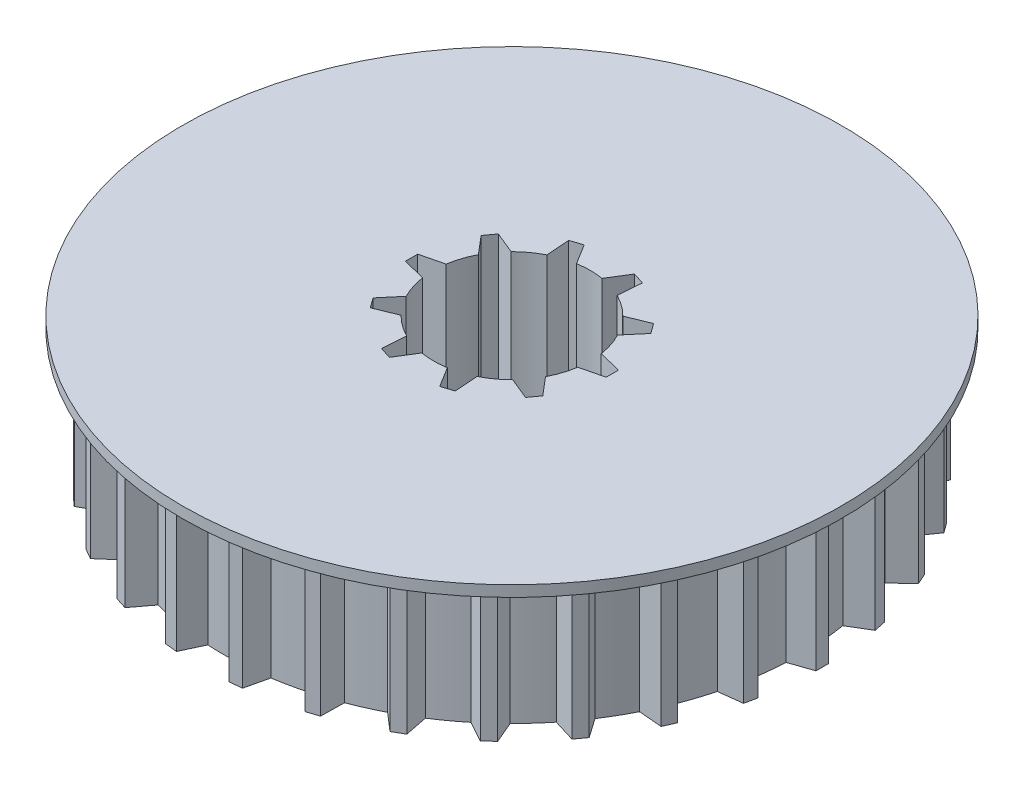
from build123d import *

# Parameters (mm, degrees)
BOSS_EXTRUDE1_DEPTH = 6.3
CIRPATTERN1_COUNT   = 30
SKETCH2_R           = 15
BOSS_EXTRUDE2_DEPTH = 0.5
CUT_EXTRUDE2_DEPTH  = 7.8
CIRPATTERN2_COUNT   = 10


with BuildPart() as part:
    # Sketch1 → Boss-Extrude1 (new body)
    with BuildSketch(Plane(origin=(0, 0, 0), x_dir=(1, 0, 0), z_dir=(0, 1, 0))):
        with BuildLine():
            ThreePointArc((13.104844929, 0.630427946), (-13.12, 0), (13.104844929, -0.630427946))
            Line((13.104844929, -0.630427946), (12.849932635, -0.718422769))
            ThreePointArc((12.849932635, -0.718422769), (12.87, 0), (12.849932635, 0.718422769))
            Line((12.849932635, 0.718422769), (13.104844929, 0.630427946))
        make_face()
        with BuildLine():
            Line((12.849932635, -0.718422769), (13.104844929, -0.630427946))
            ThreePointArc((13.104844929, -0.630427946), (13.116210685, -0.315305039), (13.12, 0))
            ThreePointArc((13.12, 0), (13.116210685, 0.315305039), (13.104844929, 0.630427946))
            Line((13.104844929, 0.630427946), (12.849932635, 0.718422769))
            ThreePointArc((12.849932635, 0.718422769), (12.87, 0), (12.849932635, -0.718422769))
        make_face()
        with BuildLine():
            Line((14.12, -0.28), (14.12, 0))
            Line((14.12, 0), (14.12, 0.28))
            Line((14.12, 0.28), (13.104844929, 0.630427946))
            ThreePointArc((13.104844929, 0.630427946), (13.116210685, 0.315305039), (13.12, 0))
            ThreePointArc((13.12, 0), (13.116210685, -0.315305039), (13.104844929, -0.630427946))
            Line((13.104844929, -0.630427946), (14.12, -0.28))
        make_face()
    boss_extrude1 = extrude(amount=BOSS_EXTRUDE1_DEPTH)

    # CirPattern1: Boss-Extrude1 ×30 about axis
    cirpattern1_axis = Axis((0, 0, 0), (0, 1, 0))
    for i in range(1, CIRPATTERN1_COUNT):
        add(boss_extrude1.rotate(cirpattern1_axis, i * 360 / CIRPATTERN1_COUNT))

    # Sketch2 → Boss-Extrude2 (add)
    with BuildSketch(Plane(origin=(0, 6.3, 0), x_dir=(1, 0, 0), z_dir=(0, 1, 0))):
        Circle(SKETCH2_R)
    extrude(amount=BOSS_EXTRUDE2_DEPTH)

    # Sketch5 → Cut-Extrude2 (cut, through all)
    with BuildSketch(Plane.XZ):
        with BuildLine():
            ThreePointArc((3.529675716, 0.535060126), (-3.57, 0), (3.529675716, -0.535060126))
            Line((3.529675716, -0.535060126), (3.265358075, -0.599863853))
            ThreePointArc((3.265358075, -0.599863853), (3.32, 0), (3.265358075, 0.599863853))
            Line((3.265358075, 0.599863853), (3.529675716, 0.535060126))
        make_face()
        with BuildLine():
            Line((3.265358075, -0.599863853), (3.529675716, -0.535060126))
            ThreePointArc((3.529675716, -0.535060126), (3.559904655, -0.268288737), (3.57, 0))
            ThreePointArc((3.57, 0), (3.559904655, 0.268288737), (3.529675716, 0.535060126))
            Line((3.529675716, 0.535060126), (3.265358075, 0.599863853))
            ThreePointArc((3.265358075, 0.599863853), (3.32, 0), (3.265358075, -0.599863853))
        make_face()
        with BuildLine():
            Line((4.57, -0.28), (4.57, 0))
            Line((4.57, 0), (4.57, 0.28))
            Line((4.57, 0.28), (3.529675716, 0.535060126))
            ThreePointArc((3.529675716, 0.535060126), (3.559904655, 0.268288737), (3.57, 0))
            ThreePointArc((3.57, 0), (3.559904655, -0.268288737), (3.529675716, -0.535060126))
            Line((3.529675716, -0.535060126), (4.57, -0.28))
        make_face()
    cut_extrude2 = extrude(amount=-CUT_EXTRUDE2_DEPTH, mode=Mode.SUBTRACT)

    # CirPattern2: Cut-Extrude2 ×10 about axis
    cirpattern2_axis = Axis((0, 0, 0), (0, 1, 0))
    for i in range(1, CIRPATTERN2_COUNT):
        add(cut_extrude2.rotate(cirpattern2_axis, i * 360 / CIRPATTERN2_COUNT), mode=Mode.SUBTRACT)


solid = part.part
